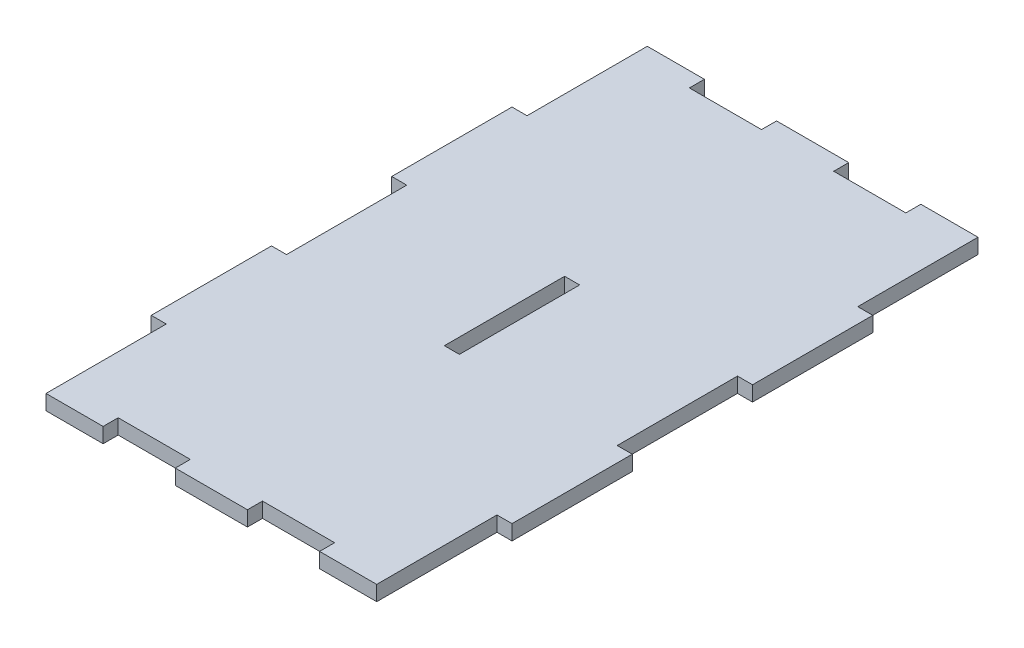
from build123d import *

# Parameters (mm, degrees)
SKETCH1_W           = 76.2
SKETCH1_H           = 127
BOSS_EXTRUDE1_DEPTH = 3.175
SKETCH2_W           = 3.175
SKETCH2_H           = 25.4
CUT_EXTRUDE1_DEPTH  = 3.175
LPATTERN1_COUNT     = 3
LPATTERN1_PITCH     = 50.8
SKETCH3_W           = 15.24
SKETCH3_H           = 3.175
CUT_EXTRUDE2_DEPTH  = 3.175
LPATTERN2_COUNT     = 3
LPATTERN2_PITCH     = 30.48
SKETCH4_W           = 3.175
SKETCH4_H           = 25.4
CUT_EXTRUDE3_DEPTH  = 3.175


with BuildPart() as part:
    # Sketch1 → Boss-Extrude1 (new body)
    with BuildSketch(Plane(origin=(0, 0, 0), x_dir=(1, 0, 0), z_dir=(0, 1, 0))):
        Rectangle(SKETCH1_W, SKETCH1_H)
    extrude(amount=BOSS_EXTRUDE1_DEPTH)

    # Sketch2 → Cut-Extrude1 (cut)
    with BuildSketch(Plane(origin=(0, 3.175, 0), x_dir=(1, 0, 0), z_dir=(0, 1, 0))):
        with Locations((-36.5125, 50.8)):
            Rectangle(SKETCH2_W, SKETCH2_H)
        with Locations((36.5125, 50.8)):
            Rectangle(SKETCH2_W, SKETCH2_H)
    cut_extrude1 = extrude(amount=-CUT_EXTRUDE1_DEPTH, mode=Mode.SUBTRACT)

    # LPattern1: Cut-Extrude1 ×3
    with Locations(*[(0, 0, i * LPATTERN1_PITCH) for i in range(1, LPATTERN1_COUNT)]):
        add(cut_extrude1, mode=Mode.SUBTRACT)

    # Sketch3 → Cut-Extrude2 (cut)
    with BuildSketch(Plane(origin=(0, 3.175, 0), x_dir=(1, 0, 0), z_dir=(0, 1, 0))):
        with Locations((15.24, 61.9125)):
            Rectangle(SKETCH3_W, SKETCH3_H)
        with Locations((15.24, -61.9125)):
            Rectangle(SKETCH3_W, SKETCH3_H)
    cut_extrude2 = extrude(amount=-CUT_EXTRUDE2_DEPTH, mode=Mode.SUBTRACT)

    # LPattern2: Cut-Extrude2 ×3
    with Locations(*[(-i * LPATTERN2_PITCH, 0, 0) for i in range(1, LPATTERN2_COUNT)]):
        add(cut_extrude2, mode=Mode.SUBTRACT)

    # Sketch4 → Cut-Extrude3 (cut)
    with BuildSketch(Plane(origin=(0, 3.175, 0), x_dir=(1, 0, 0), z_dir=(0, 1, 0))):
        Rectangle(SKETCH4_W, SKETCH4_H)
    extrude(amount=-CUT_EXTRUDE3_DEPTH, mode=Mode.SUBTRACT)


solid = part.part
